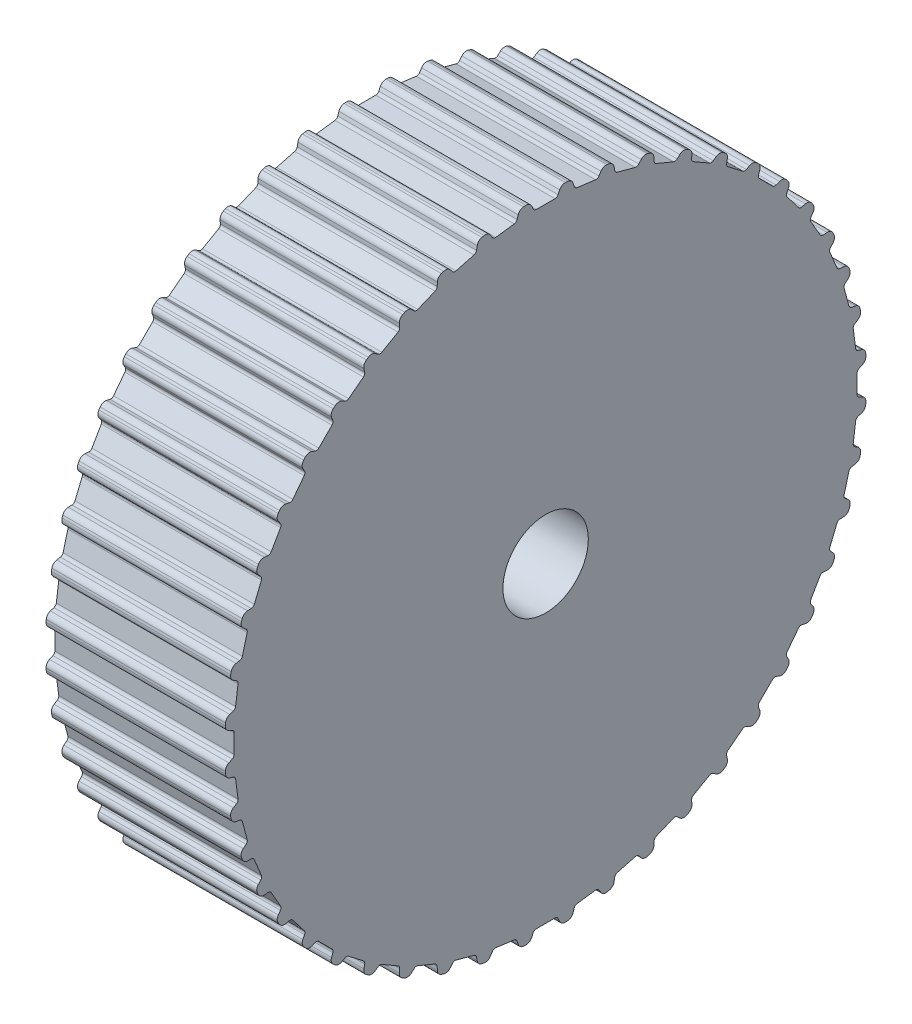
from build123d import *

# Parameters (mm, degrees)
SKETCH1_W                    = 21
SKETCH1_H                    = 37.585
CUT_EXTRUDE1_DEPTH           = 58.151241894
CUT_EXTRUDE2_DEPTH           = 58.151241894
CUT_EXTRUDE3_DEPTH           = 58.151241894
CUT_EXTRUDE4_DEPTH           = 58.151241894
CUT_EXTRUDE5_DEPTH           = 58.151241894
CUT_EXTRUDE6_DEPTH           = 58.151241894
CUT_EXTRUDE7_DEPTH           = 58.151241894
CUT_EXTRUDE8_DEPTH           = 58.151241894
CUT_EXTRUDE9_DEPTH           = 58.151241894
CUT_EXTRUDE10_DEPTH          = 58.151241894
CUT_EXTRUDE11_DEPTH          = 58.151241894
CUT_EXTRUDE12_DEPTH          = 58.151241894
CUT_EXTRUDE13_DEPTH          = 58.151241894
CUT_EXTRUDE14_DEPTH          = 58.151241894
CUT_EXTRUDE15_DEPTH          = 58.151241894
CUT_EXTRUDE16_DEPTH          = 58.151241894
CUT_EXTRUDE17_DEPTH          = 58.151241894
CUT_EXTRUDE18_DEPTH          = 58.151241894
CUT_EXTRUDE19_DEPTH          = 58.151241894
CUT_EXTRUDE20_DEPTH          = 58.151241894
CUT_EXTRUDE21_DEPTH          = 58.151241894
CUT_EXTRUDE22_DEPTH          = 58.151241894
CUT_EXTRUDE23_DEPTH          = 58.151241894
CUT_EXTRUDE24_DEPTH          = 58.151241894
CUT_EXTRUDE25_DEPTH          = 58.151241894
CUT_EXTRUDE26_DEPTH          = 58.151241894
CUT_EXTRUDE27_DEPTH          = 58.151241894
CUT_EXTRUDE28_DEPTH          = 58.151241894
CUT_EXTRUDE29_DEPTH          = 58.151241894
CUT_EXTRUDE30_DEPTH          = 58.151241894
CUT_EXTRUDE31_DEPTH          = 58.151241894
CUT_EXTRUDE32_DEPTH          = 58.151241894
CUT_EXTRUDE33_DEPTH          = 58.151241894
CUT_EXTRUDE34_DEPTH          = 58.151241894
CUT_EXTRUDE35_DEPTH          = 58.151241894
CUT_EXTRUDE36_DEPTH          = 58.151241894
CUT_EXTRUDE37_DEPTH          = 58.121553949
CUT_EXTRUDE38_DEPTH          = 58.121553949
CUT_EXTRUDE39_DEPTH          = 58.121553949
CUT_EXTRUDE40_DEPTH          = 58.121553949
CUT_EXTRUDE41_DEPTH          = 58.121553949
CUT_EXTRUDE42_DEPTH          = 58.121553949
CUT_EXTRUDE43_DEPTH          = 58.121553949
CUT_EXTRUDE44_DEPTH          = 58.121553949
CUT_EXTRUDE45_DEPTH          = 58.121553949
CUT_EXTRUDE46_DEPTH          = 58.121553949
CUT_EXTRUDE47_DEPTH          = 58.121553949
CUT_EXTRUDE48_DEPTH          = 58.121553949
SKETCH50_W                   = 6
SKETCH50_H                   = 25
F_8_0_8_DIAMETER_HOLE1_D     = 8
FILLET1_R                    = 0.4
FILLET2_R                    = 0.7
SKETCH53_R                   = 5
CUT_EXTRUDE49_DEPTH          = 60.529037311
SKETCH54_R                   = 25
CUT_EXTRUDE50_DEPTH          = 6
SKETCH55_R                   = 4.5
CUT_EXTRUDE51_DEPTH          = 17.59
TAP_DRILL_FOR_M5_TAP1_REACH  = 71.462
TAP_DRILL_FOR_M5_TAP1_BORE_R = 2.1


with BuildPart() as part:
    # Sketch1 → Revolve1 (revolve)
    with BuildSketch(Plane(origin=(0, 0, 0), x_dir=(-1, 0, 0), z_dir=(0, 0, -1)), mode=Mode.PRIVATE) as revolve1_sk:
        with Locations((-10.5, 18.7925)):
            Rectangle(SKETCH1_W, SKETCH1_H)
    revolve(revolve1_sk.sketch.rotate(Axis((21, 0, 0), (-1, 0, 0)), 270), axis=Axis((21, 0, 0), (-1, 0, 0)))

    # Sketch2 → Cut-Extrude1 (cut, through all)
    with BuildSketch(Plane.ZY):
        with BuildLine():
            Line((3.073809439, 37.459096633), (3.42379756, 36.349076127))
            Line((3.42379756, 36.349076127), (6.100698686, 35.996655408))
            Line((6.100698686, 35.996655408), (6.726055698, 36.978269291))
            ThreePointArc((6.726055698, 36.978269291), (4.905826935, 37.263455115), (3.073809439, 37.459096633))
        make_face()
    extrude(amount=-CUT_EXTRUDE1_DEPTH, mode=Mode.SUBTRACT)

    # Sketch3 → Cut-Extrude2 (cut, through all)
    with BuildSketch(Plane.ZY):
        with BuildLine():
            Line((7.936905821, 36.737416226), (8.139012995, 35.591209483))
            Line((8.139012995, 35.591209483), (10.747012726, 34.892398061))
            Line((10.747012726, 34.892398061), (11.495146045, 35.783988632))
            ThreePointArc((11.495146045, 35.783988632), (9.72771381, 36.304322181), (7.936905821, 36.737416226))
        make_face()
    extrude(amount=-CUT_EXTRUDE2_DEPTH, mode=Mode.SUBTRACT)

    # Sketch4 → Cut-Extrude3 (cut, through all)
    with BuildSketch(Plane.ZY):
        with BuildLine():
            Line((12.664199543, 35.387148443), (12.714967661, 34.224367377))
            Line((12.714967661, 34.224367377), (15.209442399, 33.19112211))
            Line((15.209442399, 33.19112211), (16.067551256, 33.977434006))
            ThreePointArc((16.067551256, 33.977434006), (14.383156805, 34.724012229), (12.664199543, 35.387148443))
        make_face()
    extrude(amount=-CUT_EXTRUDE3_DEPTH, mode=Mode.SUBTRACT)

    # Sketch5 → Cut-Extrude4 (cut, through all)
    with BuildSketch(Plane.ZY):
        with BuildLine():
            Line((17.1748053, 33.431396739), (17.073365705, 32.271936857))
            Line((17.073365705, 32.271936857), (19.411634295, 30.921936857))
            Line((19.411634295, 30.921936857), (20.365036209, 31.589516064))
            ThreePointArc((20.365036209, 31.589516064), (18.7925, 32.549564801), (17.1748053, 33.431396739))
        make_face()
    extrude(amount=-CUT_EXTRUDE4_DEPTH, mode=Mode.SUBTRACT)

    # Sketch6 → Cut-Extrude5 (cut, through all)
    with BuildSketch(Plane.ZY):
        with BuildLine():
            Line((21.391545377, 30.903624567), (21.139633728, 29.76732455))
            Line((21.139633728, 29.76732455), (23.281687747, 28.123668691))
            Line((23.281687747, 28.123668691), (24.314069748, 28.661092745))
            ThreePointArc((24.314069748, 28.661092745), (22.880298309, 29.818185295), (21.391545377, 30.903624567))
        make_face()
    extrude(amount=-CUT_EXTRUDE5_DEPTH, mode=Mode.SUBTRACT)

    # Sketch7 → Cut-Extrude6 (cut, through all)
    with BuildSketch(Plane.ZY):
        with BuildLine():
            Line((25.242270181, 27.847082811), (24.844196757, 26.753385066))
            Line((24.844196757, 26.753385066), (26.753385066, 24.844196757))
            Line((26.753385066, 24.844196757), (27.847082811, 25.242270181))
            ThreePointArc((27.847082811, 25.242270181), (26.576608371, 26.576608371), (25.242270181, 27.847082811))
        make_face()
    extrude(amount=-CUT_EXTRUDE6_DEPTH, mode=Mode.SUBTRACT)

    # Sketch8 → Cut-Extrude7 (cut, through all)
    with BuildSketch(Plane.ZY):
        with BuildLine():
            Line((28.661092745, 24.314069748), (28.123668691, 23.281687747))
            Line((28.123668691, 23.281687747), (29.76732455, 21.139633728))
            Line((29.76732455, 21.139633728), (30.903624567, 21.391545377))
            ThreePointArc((30.903624567, 21.391545377), (29.818185295, 22.880298309), (28.661092745, 24.314069748))
        make_face()
    extrude(amount=-CUT_EXTRUDE7_DEPTH, mode=Mode.SUBTRACT)

    # Sketch9 → Cut-Extrude8 (cut, through all)
    with BuildSketch(Plane.ZY):
        with BuildLine():
            Line((31.589516064, 20.365036209), (30.921936857, 19.411634295))
            Line((30.921936857, 19.411634295), (32.271936857, 17.073365705))
            Line((32.271936857, 17.073365705), (33.431396739, 17.1748053))
            ThreePointArc((33.431396739, 17.1748053), (32.549564801, 18.7925), (31.589516064, 20.365036209))
        make_face()
    extrude(amount=-CUT_EXTRUDE8_DEPTH, mode=Mode.SUBTRACT)

    # Sketch10 → Cut-Extrude9 (cut, through all)
    with BuildSketch(Plane.ZY):
        with BuildLine():
            Line((33.977434006, 16.067551256), (33.19112211, 15.209442399))
            Line((33.19112211, 15.209442399), (34.224367377, 12.714967661))
            Line((34.224367377, 12.714967661), (35.387148443, 12.664199543))
            ThreePointArc((35.387148443, 12.664199543), (34.724012229, 14.383156805), (33.977434006, 16.067551256))
        make_face()
    extrude(amount=-CUT_EXTRUDE9_DEPTH, mode=Mode.SUBTRACT)

    # Sketch11 → Cut-Extrude10 (cut, through all)
    with BuildSketch(Plane.ZY):
        with BuildLine():
            Line((35.783988632, 11.495146045), (34.892398061, 10.747012726))
            Line((34.892398061, 10.747012726), (35.591209483, 8.139012995))
            Line((35.591209483, 8.139012995), (36.737416226, 7.936905821))
            ThreePointArc((36.737416226, 7.936905821), (36.304322181, 9.72771381), (35.783988632, 11.495146045))
        make_face()
    extrude(amount=-CUT_EXTRUDE10_DEPTH, mode=Mode.SUBTRACT)

    # Sketch12 → Cut-Extrude11 (cut, through all)
    with BuildSketch(Plane.ZY):
        with BuildLine():
            Line((36.978269291, 6.726055698), (35.996655408, 6.100698686))
            Line((35.996655408, 6.100698686), (36.349076127, 3.42379756))
            Line((36.349076127, 3.42379756), (37.459096633, 3.073809439))
            ThreePointArc((37.459096633, 3.073809439), (37.263455115, 4.905826935), (36.978269291, 6.726055698))
        make_face()
    extrude(amount=-CUT_EXTRUDE11_DEPTH, mode=Mode.SUBTRACT)

    # Sketch13 → Cut-Extrude12 (cut, through all)
    with BuildSketch(Plane.ZY):
        with BuildLine():
            Line((37.53984151, 1.841880674), (36.485, 1.35))
            Line((36.485, 1.35), (36.485, -1.35))
            Line((36.485, -1.35), (37.53984151, -1.841880674))
            ThreePointArc((37.53984151, -1.841880674), (37.585, 0), (37.53984151, 1.841880674))
        make_face()
    extrude(amount=-CUT_EXTRUDE12_DEPTH, mode=Mode.SUBTRACT)

    # Sketch14 → Cut-Extrude13 (cut, through all)
    with BuildSketch(Plane.ZY):
        with BuildLine():
            Line((37.459096633, -3.073809439), (36.349076127, -3.42379756))
            Line((36.349076127, -3.42379756), (35.996655408, -6.100698686))
            Line((35.996655408, -6.100698686), (36.978269291, -6.726055698))
            ThreePointArc((36.978269291, -6.726055698), (37.263455115, -4.905826935), (37.459096633, -3.073809439))
        make_face()
    extrude(amount=-CUT_EXTRUDE13_DEPTH, mode=Mode.SUBTRACT)

    # Sketch15 → Cut-Extrude14 (cut, through all)
    with BuildSketch(Plane.ZY):
        with BuildLine():
            Line((36.737416226, -7.936905821), (35.591209483, -8.139012995))
            Line((35.591209483, -8.139012995), (34.892398061, -10.747012726))
            Line((34.892398061, -10.747012726), (35.783988632, -11.495146045))
            ThreePointArc((35.783988632, -11.495146045), (36.304322181, -9.72771381), (36.737416226, -7.936905821))
        make_face()
    extrude(amount=-CUT_EXTRUDE14_DEPTH, mode=Mode.SUBTRACT)

    # Sketch16 → Cut-Extrude15 (cut, through all)
    with BuildSketch(Plane.ZY):
        with BuildLine():
            Line((35.387148443, -12.664199543), (34.224367377, -12.714967661))
            Line((34.224367377, -12.714967661), (33.19112211, -15.209442399))
            Line((33.19112211, -15.209442399), (33.977434006, -16.067551256))
            ThreePointArc((33.977434006, -16.067551256), (34.724012229, -14.383156805), (35.387148443, -12.664199543))
        make_face()
    extrude(amount=-CUT_EXTRUDE15_DEPTH, mode=Mode.SUBTRACT)

    # Sketch17 → Cut-Extrude16 (cut, through all)
    with BuildSketch(Plane.ZY):
        with BuildLine():
            Line((33.431396739, -17.1748053), (32.271936857, -17.073365705))
            Line((32.271936857, -17.073365705), (30.921936857, -19.411634295))
            Line((30.921936857, -19.411634295), (31.589516064, -20.365036209))
            ThreePointArc((31.589516064, -20.365036209), (32.549564801, -18.7925), (33.431396739, -17.1748053))
        make_face()
    extrude(amount=-CUT_EXTRUDE16_DEPTH, mode=Mode.SUBTRACT)

    # Sketch18 → Cut-Extrude17 (cut, through all)
    with BuildSketch(Plane.ZY):
        with BuildLine():
            Line((30.903624567, -21.391545377), (29.76732455, -21.139633728))
            Line((29.76732455, -21.139633728), (28.123668691, -23.281687747))
            Line((28.123668691, -23.281687747), (28.661092745, -24.314069748))
            ThreePointArc((28.661092745, -24.314069748), (29.818185295, -22.880298309), (30.903624567, -21.391545377))
        make_face()
    extrude(amount=-CUT_EXTRUDE17_DEPTH, mode=Mode.SUBTRACT)

    # Sketch19 → Cut-Extrude18 (cut, through all)
    with BuildSketch(Plane.ZY):
        with BuildLine():
            Line((27.847082811, -25.242270181), (26.753385066, -24.844196757))
            Line((26.753385066, -24.844196757), (24.844196757, -26.753385066))
            Line((24.844196757, -26.753385066), (25.242270181, -27.847082811))
            ThreePointArc((25.242270181, -27.847082811), (26.576608371, -26.576608371), (27.847082811, -25.242270181))
        make_face()
    extrude(amount=-CUT_EXTRUDE18_DEPTH, mode=Mode.SUBTRACT)

    # Sketch20 → Cut-Extrude19 (cut, through all)
    with BuildSketch(Plane.ZY):
        with BuildLine():
            Line((24.314069748, -28.661092745), (23.281687747, -28.123668691))
            Line((23.281687747, -28.123668691), (21.139633728, -29.76732455))
            Line((21.139633728, -29.76732455), (21.391545377, -30.903624567))
            ThreePointArc((21.391545377, -30.903624567), (22.880298309, -29.818185295), (24.314069748, -28.661092745))
        make_face()
    extrude(amount=-CUT_EXTRUDE19_DEPTH, mode=Mode.SUBTRACT)

    # Sketch21 → Cut-Extrude20 (cut, through all)
    with BuildSketch(Plane.ZY):
        with BuildLine():
            Line((20.365036209, -31.589516064), (19.411634295, -30.921936857))
            Line((19.411634295, -30.921936857), (17.073365705, -32.271936857))
            Line((17.073365705, -32.271936857), (17.1748053, -33.431396739))
            ThreePointArc((17.1748053, -33.431396739), (18.7925, -32.549564801), (20.365036209, -31.589516064))
        make_face()
    extrude(amount=-CUT_EXTRUDE20_DEPTH, mode=Mode.SUBTRACT)

    # Sketch22 → Cut-Extrude21 (cut, through all)
    with BuildSketch(Plane.ZY):
        with BuildLine():
            Line((16.067551256, -33.977434006), (15.209442399, -33.19112211))
            Line((15.209442399, -33.19112211), (12.714967661, -34.224367377))
            Line((12.714967661, -34.224367377), (12.664199543, -35.387148443))
            ThreePointArc((12.664199543, -35.387148443), (14.383156805, -34.724012229), (16.067551256, -33.977434006))
        make_face()
    extrude(amount=-CUT_EXTRUDE21_DEPTH, mode=Mode.SUBTRACT)

    # Sketch23 → Cut-Extrude22 (cut, through all)
    with BuildSketch(Plane.ZY):
        with BuildLine():
            Line((11.495146045, -35.783988632), (10.747012726, -34.892398061))
            Line((10.747012726, -34.892398061), (8.139012995, -35.591209483))
            Line((8.139012995, -35.591209483), (7.936905821, -36.737416226))
            ThreePointArc((7.936905821, -36.737416226), (9.72771381, -36.304322181), (11.495146045, -35.783988632))
        make_face()
    extrude(amount=-CUT_EXTRUDE22_DEPTH, mode=Mode.SUBTRACT)

    # Sketch24 → Cut-Extrude23 (cut, through all)
    with BuildSketch(Plane.ZY):
        with BuildLine():
            Line((6.726055698, -36.978269291), (6.100698686, -35.996655408))
            Line((6.100698686, -35.996655408), (3.42379756, -36.349076127))
            Line((3.42379756, -36.349076127), (3.073809439, -37.459096633))
            ThreePointArc((3.073809439, -37.459096633), (4.905826935, -37.263455115), (6.726055698, -36.978269291))
        make_face()
    extrude(amount=-CUT_EXTRUDE23_DEPTH, mode=Mode.SUBTRACT)

    # Sketch25 → Cut-Extrude24 (cut, through all)
    with BuildSketch(Plane.ZY):
        with BuildLine():
            Line((1.841880674, -37.53984151), (1.35, -36.485))
            Line((1.35, -36.485), (-1.35, -36.485))
            Line((-1.35, -36.485), (-1.841880674, -37.53984151))
            ThreePointArc((-1.841880674, -37.53984151), (0, -37.585), (1.841880674, -37.53984151))
        make_face()
    extrude(amount=-CUT_EXTRUDE24_DEPTH, mode=Mode.SUBTRACT)

    # Sketch26 → Cut-Extrude25 (cut, through all)
    with BuildSketch(Plane.ZY):
        with BuildLine():
            Line((-3.073809439, -37.459096633), (-3.42379756, -36.349076127))
            Line((-3.42379756, -36.349076127), (-6.100698686, -35.996655408))
            Line((-6.100698686, -35.996655408), (-6.726055698, -36.978269291))
            ThreePointArc((-6.726055698, -36.978269291), (-4.905826935, -37.263455115), (-3.073809439, -37.459096633))
        make_face()
    extrude(amount=-CUT_EXTRUDE25_DEPTH, mode=Mode.SUBTRACT)

    # Sketch27 → Cut-Extrude26 (cut, through all)
    with BuildSketch(Plane.ZY):
        with BuildLine():
            Line((-7.936905821, -36.737416226), (-8.139012995, -35.591209483))
            Line((-8.139012995, -35.591209483), (-10.747012726, -34.892398061))
            Line((-10.747012726, -34.892398061), (-11.495146045, -35.783988632))
            ThreePointArc((-11.495146045, -35.783988632), (-9.72771381, -36.304322181), (-7.936905821, -36.737416226))
        make_face()
    extrude(amount=-CUT_EXTRUDE26_DEPTH, mode=Mode.SUBTRACT)

    # Sketch28 → Cut-Extrude27 (cut, through all)
    with BuildSketch(Plane.ZY):
        with BuildLine():
            Line((-12.664199543, -35.387148443), (-12.714967661, -34.224367377))
            Line((-12.714967661, -34.224367377), (-15.209442399, -33.19112211))
            Line((-15.209442399, -33.19112211), (-16.067551256, -33.977434006))
            ThreePointArc((-16.067551256, -33.977434006), (-14.383156805, -34.724012229), (-12.664199543, -35.387148443))
        make_face()
    extrude(amount=-CUT_EXTRUDE27_DEPTH, mode=Mode.SUBTRACT)

    # Sketch29 → Cut-Extrude28 (cut, through all)
    with BuildSketch(Plane.ZY):
        with BuildLine():
            Line((-17.1748053, -33.431396739), (-17.073365705, -32.271936857))
            Line((-17.073365705, -32.271936857), (-19.411634295, -30.921936857))
            Line((-19.411634295, -30.921936857), (-20.365036209, -31.589516064))
            ThreePointArc((-20.365036209, -31.589516064), (-18.7925, -32.549564801), (-17.1748053, -33.431396739))
        make_face()
    extrude(amount=-CUT_EXTRUDE28_DEPTH, mode=Mode.SUBTRACT)

    # Sketch30 → Cut-Extrude29 (cut, through all)
    with BuildSketch(Plane.ZY):
        with BuildLine():
            Line((-21.391545377, -30.903624567), (-21.139633728, -29.76732455))
            Line((-21.139633728, -29.76732455), (-23.281687747, -28.123668691))
            Line((-23.281687747, -28.123668691), (-24.314069748, -28.661092745))
            ThreePointArc((-24.314069748, -28.661092745), (-22.880298309, -29.818185295), (-21.391545377, -30.903624567))
        make_face()
    extrude(amount=-CUT_EXTRUDE29_DEPTH, mode=Mode.SUBTRACT)

    # Sketch31 → Cut-Extrude30 (cut, through all)
    with BuildSketch(Plane.ZY):
        with BuildLine():
            Line((-25.242270181, -27.847082811), (-24.844196757, -26.753385066))
            Line((-24.844196757, -26.753385066), (-26.753385066, -24.844196757))
            Line((-26.753385066, -24.844196757), (-27.847082811, -25.242270181))
            ThreePointArc((-27.847082811, -25.242270181), (-26.576608371, -26.576608371), (-25.242270181, -27.847082811))
        make_face()
    extrude(amount=-CUT_EXTRUDE30_DEPTH, mode=Mode.SUBTRACT)

    # Sketch32 → Cut-Extrude31 (cut, through all)
    with BuildSketch(Plane.ZY):
        with BuildLine():
            Line((-28.661092745, -24.314069748), (-28.123668691, -23.281687747))
            Line((-28.123668691, -23.281687747), (-29.76732455, -21.139633728))
            Line((-29.76732455, -21.139633728), (-30.903624567, -21.391545377))
            ThreePointArc((-30.903624567, -21.391545377), (-29.818185295, -22.880298309), (-28.661092745, -24.314069748))
        make_face()
    extrude(amount=-CUT_EXTRUDE31_DEPTH, mode=Mode.SUBTRACT)

    # Sketch33 → Cut-Extrude32 (cut, through all)
    with BuildSketch(Plane.ZY):
        with BuildLine():
            Line((-31.589516064, -20.365036209), (-30.921936857, -19.411634295))
            Line((-30.921936857, -19.411634295), (-32.271936857, -17.073365705))
            Line((-32.271936857, -17.073365705), (-33.431396739, -17.1748053))
            ThreePointArc((-33.431396739, -17.1748053), (-32.549564801, -18.7925), (-31.589516064, -20.365036209))
        make_face()
    extrude(amount=-CUT_EXTRUDE32_DEPTH, mode=Mode.SUBTRACT)

    # Sketch34 → Cut-Extrude33 (cut, through all)
    with BuildSketch(Plane.ZY):
        with BuildLine():
            Line((-33.977434006, -16.067551256), (-33.19112211, -15.209442399))
            Line((-33.19112211, -15.209442399), (-34.224367377, -12.714967661))
            Line((-34.224367377, -12.714967661), (-35.387148443, -12.664199543))
            ThreePointArc((-35.387148443, -12.664199543), (-34.724012229, -14.383156805), (-33.977434006, -16.067551256))
        make_face()
    extrude(amount=-CUT_EXTRUDE33_DEPTH, mode=Mode.SUBTRACT)

    # Sketch35 → Cut-Extrude34 (cut, through all)
    with BuildSketch(Plane.ZY):
        with BuildLine():
            Line((-35.783988632, -11.495146045), (-34.892398061, -10.747012726))
            Line((-34.892398061, -10.747012726), (-35.591209483, -8.139012995))
            Line((-35.591209483, -8.139012995), (-36.737416226, -7.936905821))
            ThreePointArc((-36.737416226, -7.936905821), (-36.304322181, -9.72771381), (-35.783988632, -11.495146045))
        make_face()
    extrude(amount=-CUT_EXTRUDE34_DEPTH, mode=Mode.SUBTRACT)

    # Sketch36 → Cut-Extrude35 (cut, through all)
    with BuildSketch(Plane.ZY):
        with BuildLine():
            Line((-36.978269291, -6.726055698), (-35.996655408, -6.100698686))
            Line((-35.996655408, -6.100698686), (-36.349076127, -3.42379756))
            Line((-36.349076127, -3.42379756), (-37.459096633, -3.073809439))
            ThreePointArc((-37.459096633, -3.073809439), (-37.263455115, -4.905826935), (-36.978269291, -6.726055698))
        make_face()
    extrude(amount=-CUT_EXTRUDE35_DEPTH, mode=Mode.SUBTRACT)

    # Sketch37 → Cut-Extrude36 (cut, through all)
    with BuildSketch(Plane.ZY):
        with BuildLine():
            Line((-37.53984151, -1.841880674), (-36.485, -1.35))
            Line((-36.485, -1.35), (-36.485, 1.35))
            Line((-36.485, 1.35), (-37.53984151, 1.841880674))
            ThreePointArc((-37.53984151, 1.841880674), (-37.585, 0), (-37.53984151, -1.841880674))
        make_face()
    extrude(amount=-CUT_EXTRUDE36_DEPTH, mode=Mode.SUBTRACT)

    # Sketch38 → Cut-Extrude37 (cut, through all)
    with BuildSketch(Plane.ZY):
        with BuildLine():
            Line((-37.459096633, 3.073809439), (-36.349076127, 3.42379756))
            Line((-36.349076127, 3.42379756), (-35.996655408, 6.100698686))
            Line((-35.996655408, 6.100698686), (-36.978269291, 6.726055698))
            ThreePointArc((-36.978269291, 6.726055698), (-37.263455115, 4.905826935), (-37.459096633, 3.073809439))
        make_face()
    extrude(amount=-CUT_EXTRUDE37_DEPTH, mode=Mode.SUBTRACT)

    # Sketch39 → Cut-Extrude38 (cut, through all)
    with BuildSketch(Plane.ZY):
        with BuildLine():
            Line((-36.737416226, 7.936905821), (-35.591209483, 8.139012995))
            Line((-35.591209483, 8.139012995), (-34.892398061, 10.747012726))
            Line((-34.892398061, 10.747012726), (-35.783988632, 11.495146045))
            ThreePointArc((-35.783988632, 11.495146045), (-36.304322181, 9.72771381), (-36.737416226, 7.936905821))
        make_face()
    extrude(amount=-CUT_EXTRUDE38_DEPTH, mode=Mode.SUBTRACT)

    # Sketch40 → Cut-Extrude39 (cut, through all)
    with BuildSketch(Plane.ZY):
        with BuildLine():
            Line((-35.387148443, 12.664199543), (-34.224367377, 12.714967661))
            Line((-34.224367377, 12.714967661), (-33.19112211, 15.209442399))
            Line((-33.19112211, 15.209442399), (-33.977434006, 16.067551256))
            ThreePointArc((-33.977434006, 16.067551256), (-34.724012229, 14.383156805), (-35.387148443, 12.664199543))
        make_face()
    extrude(amount=-CUT_EXTRUDE39_DEPTH, mode=Mode.SUBTRACT)

    # Sketch41 → Cut-Extrude40 (cut, through all)
    with BuildSketch(Plane.ZY):
        with BuildLine():
            Line((-33.431396739, 17.1748053), (-32.271936857, 17.073365705))
            Line((-32.271936857, 17.073365705), (-30.921936857, 19.411634295))
            Line((-30.921936857, 19.411634295), (-31.589516064, 20.365036209))
            ThreePointArc((-31.589516064, 20.365036209), (-32.549564801, 18.7925), (-33.431396739, 17.1748053))
        make_face()
    extrude(amount=-CUT_EXTRUDE40_DEPTH, mode=Mode.SUBTRACT)

    # Sketch42 → Cut-Extrude41 (cut, through all)
    with BuildSketch(Plane.ZY):
        with BuildLine():
            Line((-30.903624567, 21.391545377), (-29.76732455, 21.139633728))
            Line((-29.76732455, 21.139633728), (-28.123668691, 23.281687747))
            Line((-28.123668691, 23.281687747), (-28.661092745, 24.314069748))
            ThreePointArc((-28.661092745, 24.314069748), (-29.818185295, 22.880298309), (-30.903624567, 21.391545377))
        make_face()
    extrude(amount=-CUT_EXTRUDE41_DEPTH, mode=Mode.SUBTRACT)

    # Sketch43 → Cut-Extrude42 (cut, through all)
    with BuildSketch(Plane.ZY):
        with BuildLine():
            Line((-27.847082811, 25.242270181), (-26.753385066, 24.844196757))
            Line((-26.753385066, 24.844196757), (-24.844196757, 26.753385066))
            Line((-24.844196757, 26.753385066), (-25.242270181, 27.847082811))
            ThreePointArc((-25.242270181, 27.847082811), (-26.576608371, 26.576608371), (-27.847082811, 25.242270181))
        make_face()
    extrude(amount=-CUT_EXTRUDE42_DEPTH, mode=Mode.SUBTRACT)

    # Sketch44 → Cut-Extrude43 (cut, through all)
    with BuildSketch(Plane.ZY):
        with BuildLine():
            Line((-24.314069748, 28.661092745), (-23.281687747, 28.123668691))
            Line((-23.281687747, 28.123668691), (-21.139633728, 29.76732455))
            Line((-21.139633728, 29.76732455), (-21.391545377, 30.903624567))
            ThreePointArc((-21.391545377, 30.903624567), (-22.880298309, 29.818185295), (-24.314069748, 28.661092745))
        make_face()
    extrude(amount=-CUT_EXTRUDE43_DEPTH, mode=Mode.SUBTRACT)

    # Sketch45 → Cut-Extrude44 (cut, through all)
    with BuildSketch(Plane.ZY):
        with BuildLine():
            Line((-20.365036209, 31.589516064), (-19.411634295, 30.921936857))
            Line((-19.411634295, 30.921936857), (-17.073365705, 32.271936857))
            Line((-17.073365705, 32.271936857), (-17.1748053, 33.431396739))
            ThreePointArc((-17.1748053, 33.431396739), (-18.7925, 32.549564801), (-20.365036209, 31.589516064))
        make_face()
    extrude(amount=-CUT_EXTRUDE44_DEPTH, mode=Mode.SUBTRACT)

    # Sketch46 → Cut-Extrude45 (cut, through all)
    with BuildSketch(Plane.ZY):
        with BuildLine():
            Line((-16.067551256, 33.977434006), (-15.209442399, 33.19112211))
            Line((-15.209442399, 33.19112211), (-12.714967661, 34.224367377))
            Line((-12.714967661, 34.224367377), (-12.664199543, 35.387148443))
            ThreePointArc((-12.664199543, 35.387148443), (-14.383156805, 34.724012229), (-16.067551256, 33.977434006))
        make_face()
    extrude(amount=-CUT_EXTRUDE45_DEPTH, mode=Mode.SUBTRACT)

    # Sketch47 → Cut-Extrude46 (cut, through all)
    with BuildSketch(Plane.ZY):
        with BuildLine():
            Line((-11.495146045, 35.783988632), (-10.747012726, 34.892398061))
            Line((-10.747012726, 34.892398061), (-8.139012995, 35.591209483))
            Line((-8.139012995, 35.591209483), (-7.936905821, 36.737416226))
            ThreePointArc((-7.936905821, 36.737416226), (-9.72771381, 36.304322181), (-11.495146045, 35.783988632))
        make_face()
    extrude(amount=-CUT_EXTRUDE46_DEPTH, mode=Mode.SUBTRACT)

    # Sketch48 → Cut-Extrude47 (cut, through all)
    with BuildSketch(Plane.ZY):
        with BuildLine():
            Line((-6.726055698, 36.978269291), (-6.100698686, 35.996655408))
            Line((-6.100698686, 35.996655408), (-3.42379756, 36.349076127))
            Line((-3.42379756, 36.349076127), (-3.073809439, 37.459096633))
            ThreePointArc((-3.073809439, 37.459096633), (-4.905826935, 37.263455115), (-6.726055698, 36.978269291))
        make_face()
    extrude(amount=-CUT_EXTRUDE47_DEPTH, mode=Mode.SUBTRACT)

    # Sketch49 → Cut-Extrude48 (cut, through all)
    with BuildSketch(Plane.ZY):
        with BuildLine():
            Line((-1.841880674, 37.53984151), (-1.35, 36.485))
            Line((-1.35, 36.485), (1.35, 36.485))
            Line((1.35, 36.485), (1.841880674, 37.53984151))
            ThreePointArc((1.841880674, 37.53984151), (0, 37.585), (-1.841880674, 37.53984151))
        make_face()
    extrude(amount=-CUT_EXTRUDE48_DEPTH, mode=Mode.SUBTRACT)

    # Sketch50 → Revolve2 (revolve)
    with BuildSketch(Plane(origin=(0, 0, 0), x_dir=(-1, 0, 0), z_dir=(0, 0, -1)), mode=Mode.PRIVATE) as revolve2_sk:
        with Locations((-24, 12.5)):
            Rectangle(SKETCH50_W, SKETCH50_H)
    revolve(revolve2_sk.sketch.rotate(Axis((27, 0, 0), (-1, 0, 0)), 270), axis=Axis((27, 0, 0), (-1, 0, 0)))

    # Ø8.0 (8) Diameter Hole1 (through all)
    with Locations(Plane(origin=(27, 0, 0), x_dir=(0, 0, -1), z_dir=(1, 0, 0))):
        with Locations((0, 0)):
            Hole(F_8_0_8_DIAMETER_HOLE1_D / 2)

    # Fillet1
    fillet1_edges = [part.edges().sort_by_distance(p)[0] for p in [
        (10.5, 21.139633728, 29.76732455),
        (10.5, 23.281687747, 28.123668691),
        (10.5, 17.073365705, 32.271936857),
        (10.5, 19.411634295, 30.921936857),
        (10.5, 35.996655408, 6.100698686),
        (10.5, 12.714967661, 34.224367377),
        (10.5, 15.209442399, 33.19112211),
        (10.5, 36.349076127, 3.42379756),
        (10.5, 8.139012995, 35.591209483),
        (10.5, 10.747012726, 34.892398061),
        (10.5, 3.42379756, 36.349076127),
        (10.5, 6.100698686, 35.996655408),
        (10.5, -1.35, 36.485),
        (10.5, 1.35, 36.485),
        (10.5, -6.100698686, 35.996655408),
        (10.5, -3.42379756, 36.349076127),
        (10.5, -10.747012726, 34.892398061),
        (10.5, -8.139012995, 35.591209483),
        (10.5, -15.209442399, 33.19112211),
        (10.5, -12.714967661, 34.224367377),
        (10.5, -19.411634295, 30.921936857),
        (10.5, -17.073365705, 32.271936857),
        (10.5, -23.281687747, 28.123668691),
        (10.5, -21.139633728, 29.76732455),
        (10.5, 34.892398061, 10.747012726),
        (10.5, -26.753385066, 24.844196757),
        (10.5, -24.844196757, 26.753385066),
        (10.5, 35.591209483, 8.139012995),
        (10.5, -29.76732455, 21.139633728),
        (10.5, -28.123668691, 23.281687747),
        (10.5, -32.271936857, 17.073365705),
        (10.5, -30.921936857, 19.411634295),
        (10.5, -34.224367377, 12.714967661),
        (10.5, -33.19112211, 15.209442399),
        (10.5, -35.591209483, 8.139012995),
        (10.5, -34.892398061, 10.747012726),
        (10.5, -36.349076127, 3.42379756),
        (10.5, -35.996655408, 6.100698686),
        (10.5, -36.485, -1.35),
        (10.5, -36.485, 1.35),
        (10.5, -35.996655408, -6.100698686),
        (10.5, -36.349076127, -3.42379756),
        (10.5, -34.892398061, -10.747012726),
        (10.5, -35.591209483, -8.139012995),
        (10.5, -33.19112211, -15.209442399),
        (10.5, -34.224367377, -12.714967661),
        (10.5, -30.921936857, -19.411634295),
        (10.5, -32.271936857, -17.073365705),
        (10.5, 33.19112211, 15.209442399),
        (10.5, 34.224367377, 12.714967661),
        (10.5, -28.123668691, -23.281687747),
        (10.5, -29.76732455, -21.139633728),
        (10.5, -24.844196757, -26.753385066),
        (10.5, -26.753385066, -24.844196757),
        (10.5, -21.139633728, -29.76732455),
        (10.5, -23.281687747, -28.123668691),
        (10.5, -17.073365705, -32.271936857),
        (10.5, -19.411634295, -30.921936857),
        (10.5, -12.714967661, -34.224367377),
        (10.5, -15.209442399, -33.19112211),
        (10.5, -8.139012995, -35.591209483),
        (10.5, -10.747012726, -34.892398061),
        (10.5, -3.42379756, -36.349076127),
        (10.5, -6.100698686, -35.996655408),
        (10.5, 1.35, -36.485),
        (10.5, -1.35, -36.485),
        (10.5, 6.100698686, -35.996655408),
        (10.5, 3.42379756, -36.349076127),
        (10.5, 10.747012726, -34.892398061),
        (10.5, 8.139012995, -35.591209483),
        (10.5, 15.209442399, -33.19112211),
        (10.5, 12.714967661, -34.224367377),
        (10.5, 30.921936857, 19.411634295),
        (10.5, 32.271936857, 17.073365705),
        (10.5, 19.411634295, -30.921936857),
        (10.5, 17.073365705, -32.271936857),
        (10.5, 23.281687747, -28.123668691),
        (10.5, 21.139633728, -29.76732455),
        (10.5, 26.753385066, -24.844196757),
        (10.5, 24.844196757, -26.753385066),
        (10.5, 29.76732455, -21.139633728),
        (10.5, 28.123668691, -23.281687747),
        (10.5, 32.271936857, -17.073365705),
        (10.5, 30.921936857, -19.411634295),
        (10.5, 34.224367377, -12.714967661),
        (10.5, 33.19112211, -15.209442399),
        (10.5, 35.591209483, -8.139012995),
        (10.5, 34.892398061, -10.747012726),
        (10.5, 36.349076127, -3.42379756),
        (10.5, 35.996655408, -6.100698686),
        (10.5, 36.485, 1.35),
        (10.5, 36.485, -1.35),
        (10.5, 28.123668691, 23.281687747),
        (10.5, 29.76732455, 21.139633728),
        (10.5, 24.844196757, 26.753385066),
        (10.5, 26.753385066, 24.844196757),
    ]]
    fillet(fillet1_edges, radius=FILLET1_R)

    # Fillet2
    fillet2_edges = [part.edges().sort_by_distance(p)[0] for p in [
        (10.5, 24.314069748, 28.661092745),
        (10.5, 21.391545377, 30.903624567),
        (10.5, 20.365036209, 31.589516064),
        (10.5, 17.1748053, 33.431396739),
        (10.5, 37.459096633, 3.073809439),
        (10.5, 36.978269291, 6.726055698),
        (10.5, 16.067551256, 33.977434006),
        (10.5, 12.664199543, 35.387148443),
        (10.5, 11.495146045, 35.783988632),
        (10.5, 7.936905821, 36.737416226),
        (10.5, 6.726055698, 36.978269291),
        (10.5, 3.073809439, 37.459096633),
        (10.5, 1.841880674, 37.53984151),
        (10.5, -1.841880674, 37.53984151),
        (10.5, -3.073809439, 37.459096633),
        (10.5, -6.726055698, 36.978269291),
        (10.5, -7.936905821, 36.737416226),
        (10.5, -11.495146045, 35.783988632),
        (10.5, -12.664199543, 35.387148443),
        (10.5, -16.067551256, 33.977434006),
        (10.5, -17.1748053, 33.431396739),
        (10.5, -20.365036209, 31.589516064),
        (10.5, -21.391545377, 30.903624567),
        (10.5, -24.314069748, 28.661092745),
        (10.5, 36.737416226, 7.936905821),
        (10.5, 35.783988632, 11.495146045),
        (10.5, -25.242270181, 27.847082811),
        (10.5, -27.847082811, 25.242270181),
        (10.5, -28.661092745, 24.314069748),
        (10.5, -30.903624567, 21.391545377),
        (10.5, -31.589516064, 20.365036209),
        (10.5, -33.431396739, 17.1748053),
        (10.5, -33.977434006, 16.067551256),
        (10.5, -35.387148443, 12.664199543),
        (10.5, -35.783988632, 11.495146045),
        (10.5, -36.737416226, 7.936905821),
        (10.5, -36.978269291, 6.726055698),
        (10.5, -37.459096633, 3.073809439),
        (10.5, -37.53984151, 1.841880674),
        (10.5, -37.53984151, -1.841880674),
        (10.5, -37.459096633, -3.073809439),
        (10.5, -36.978269291, -6.726055698),
        (10.5, -36.737416226, -7.936905821),
        (10.5, -35.783988632, -11.495146045),
        (10.5, -35.387148443, -12.664199543),
        (10.5, -33.977434006, -16.067551256),
        (10.5, -33.431396739, -17.1748053),
        (10.5, 35.387148443, 12.664199543),
        (10.5, -31.589516064, -20.365036209),
        (10.5, 33.977434006, 16.067551256),
        (10.5, -30.903624567, -21.391545377),
        (10.5, -28.661092745, -24.314069748),
        (10.5, -27.847082811, -25.242270181),
        (10.5, -25.242270181, -27.847082811),
        (10.5, -24.314069748, -28.661092745),
        (10.5, -21.391545377, -30.903624567),
        (10.5, -20.365036209, -31.589516064),
        (10.5, -17.1748053, -33.431396739),
        (10.5, -16.067551256, -33.977434006),
        (10.5, -12.664199543, -35.387148443),
        (10.5, -11.495146045, -35.783988632),
        (10.5, -7.936905821, -36.737416226),
        (10.5, -6.726055698, -36.978269291),
        (10.5, -3.073809439, -37.459096633),
        (10.5, -1.841880674, -37.53984151),
        (10.5, 1.841880674, -37.53984151),
        (10.5, 3.073809439, -37.459096633),
        (10.5, 6.726055698, -36.978269291),
        (10.5, 7.936905821, -36.737416226),
        (10.5, 11.495146045, -35.783988632),
        (10.5, 33.431396739, 17.1748053),
        (10.5, 12.664199543, -35.387148443),
        (10.5, 16.067551256, -33.977434006),
        (10.5, 31.589516064, 20.365036209),
        (10.5, 17.1748053, -33.431396739),
        (10.5, 20.365036209, -31.589516064),
        (10.5, 21.391545377, -30.903624567),
        (10.5, 24.314069748, -28.661092745),
        (10.5, 25.242270181, -27.847082811),
        (10.5, 27.847082811, -25.242270181),
        (10.5, 28.661092745, -24.314069748),
        (10.5, 30.903624567, -21.391545377),
        (10.5, 31.589516064, -20.365036209),
        (10.5, 33.431396739, -17.1748053),
        (10.5, 33.977434006, -16.067551256),
        (10.5, 35.387148443, -12.664199543),
        (10.5, 35.783988632, -11.495146045),
        (10.5, 36.737416226, -7.936905821),
        (10.5, 36.978269291, -6.726055698),
        (10.5, 37.459096633, -3.073809439),
        (10.5, 37.53984151, -1.841880674),
        (10.5, 37.53984151, 1.841880674),
        (10.5, 30.903624567, 21.391545377),
        (10.5, 28.661092745, 24.314069748),
        (10.5, 27.847082811, 25.242270181),
        (10.5, 25.242270181, 27.847082811),
    ]]
    fillet(fillet2_edges, radius=FILLET2_R)

    # Sketch53 → Cut-Extrude49 (cut, through all)
    with BuildSketch(Plane(origin=(27, 0, 0), x_dir=(0, 0, -1), z_dir=(1, 0, 0))):
        Circle(SKETCH53_R)
    extrude(amount=-CUT_EXTRUDE49_DEPTH, mode=Mode.SUBTRACT)

    # Sketch54 → Cut-Extrude50 (cut)
    with BuildSketch(Plane(origin=(27, 0, 0), x_dir=(0, 0, -1), z_dir=(1, 0, 0))):
        Circle(SKETCH54_R)
    extrude(amount=-CUT_EXTRUDE50_DEPTH, mode=Mode.SUBTRACT)

    # Sketch55 → Cut-Extrude51 (cut)
    with BuildSketch(Plane(origin=(0, -37.585, 0), x_dir=(-1, 0, 0), z_dir=(0, -1, 0))):
        with Locations(Location((-10.5, 0, 0), (0, 0, 90))):
            Circle(SKETCH55_R)
    extrude(amount=-CUT_EXTRUDE51_DEPTH, mode=Mode.SUBTRACT)

    # Tap Drill for M5 Tap1 bore (on position points) → Tap Drill for M5 Tap1 (cut, up to next)
    with BuildSketch(Plane(origin=(10.5, -19.995, 0), x_dir=(0, 0, -1), z_dir=(0, -1, 0)), mode=Mode.PRIVATE) as tap_drill_for_m5_tap1_sk1:
        Circle(TAP_DRILL_FOR_M5_TAP1_BORE_R)
    tap_drill_for_m5_tap1_tool1 = extrude(tap_drill_for_m5_tap1_sk1.sketch, amount=-TAP_DRILL_FOR_M5_TAP1_REACH, mode=Mode.PRIVATE) & part.part
    add(tap_drill_for_m5_tap1_tool1.solids().sort_by_distance((10.5, -19.995, 0))[0], mode=Mode.SUBTRACT)


solid = part.part
